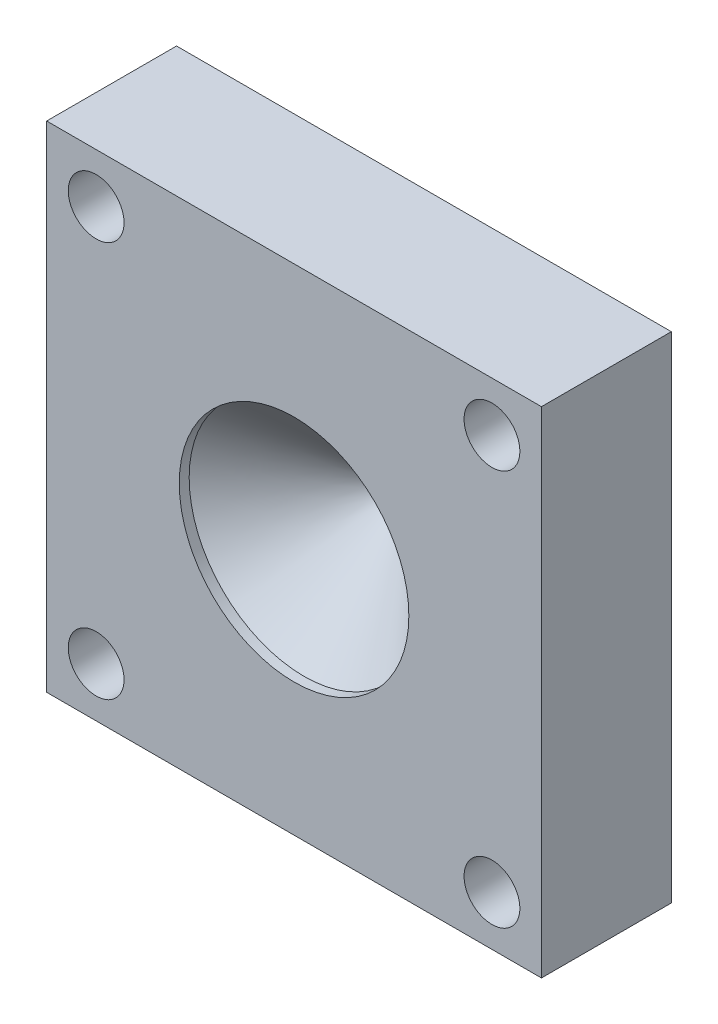
from build123d import *

# Parameters (mm, degrees)
SKETCH1_W                   = 63.5
SKETCH1_H                   = 63.5
SKETCH1_R                   = 0.79375
SKETCH1_R_2                 = 3.5814
BOSS_EXTRUDE1_DEPTH         = 16.66875
SKETCH2_R                   = 14.732
CUT_EXTRUDE1_DEPTH          = 1.27
SKETCH3_R                   = 4.827467581
SKETCH3_R_2                 = 3.154053727
SKETCH3_R_3                 = 4.493756986
CARTIDGE_HEATER_DEPTH_DEPTH = 12.7
SKETCH4_R                   = 14.732
CUT_EXTRUDE3_DEPTH          = 12.7
CUT_EXTRUDE3_TAPER          = 47.5


with BuildPart() as part:
    # Sketch1 → Boss-Extrude1 (new body)
    with BuildSketch(Plane.XY):
        Rectangle(SKETCH1_W, SKETCH1_H)
        Circle(SKETCH1_R, mode=Mode.SUBTRACT)
        with Locations((-25.4, 25.4)):
            Circle(SKETCH1_R_2, mode=Mode.SUBTRACT)
        with Locations((25.4, 25.4)):
            Circle(SKETCH1_R_2, mode=Mode.SUBTRACT)
        with Locations((25.4, -25.4)):
            Circle(SKETCH1_R_2, mode=Mode.SUBTRACT)
        with Locations((-25.4, -25.4)):
            Circle(SKETCH1_R_2, mode=Mode.SUBTRACT)
    extrude(amount=BOSS_EXTRUDE1_DEPTH)

    # Sketch2 → Cut-Extrude1 (cut)
    with BuildSketch(Plane.XY.offset(16.66875)):
        Circle(SKETCH2_R)
    extrude(amount=-CUT_EXTRUDE1_DEPTH, mode=Mode.SUBTRACT)

    # Sketch3 → Cartidge heater (??? depth) (cut)
    with BuildSketch(Plane.ZY.offset(31.75)):
        with Locations((8.252073855, 11.1125)):
            Circle(SKETCH3_R)
        with Locations((8.252073855, 0)):
            Circle(SKETCH3_R_2)
        with Locations((8.252073855, -11.1125)):
            Circle(SKETCH3_R_3)
    extrude(amount=-CARTIDGE_HEATER_DEPTH_DEPTH, mode=Mode.SUBTRACT)

    # Sketch4 → Cut-Extrude3 (cut)
    with BuildSketch(Plane.XY.offset(15.39875)):
        Circle(SKETCH4_R)
    extrude(amount=-CUT_EXTRUDE3_DEPTH, taper=CUT_EXTRUDE3_TAPER, mode=Mode.SUBTRACT)


solid = part.part
